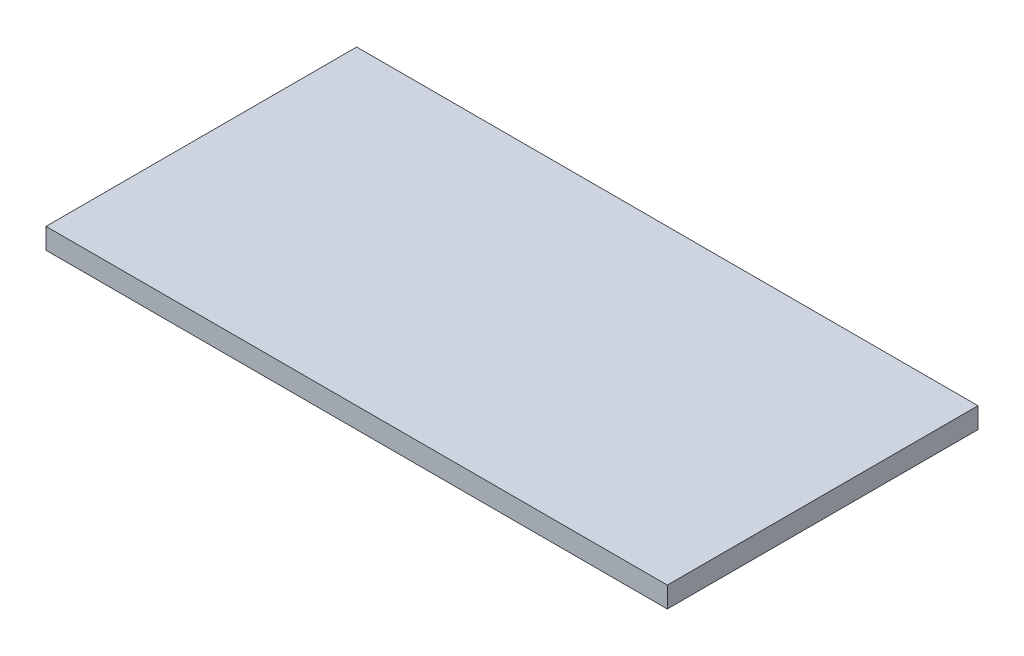
from build123d import *

# Parameters (mm, degrees)
SKETCH1_W           = 30
SKETCH1_H           = 15
BOSS_EXTRUDE1_DEPTH = 1


with BuildPart() as part:
    # Sketch1 → Boss-Extrude1 (new body)
    with BuildSketch(Plane(origin=(0, 0, 0), x_dir=(1, 0, 0), z_dir=(0, 1, 0))):
        with Locations((1.7, -0.9)):
            Rectangle(SKETCH1_W, SKETCH1_H)
    extrude(amount=BOSS_EXTRUDE1_DEPTH)


solid = part.part
